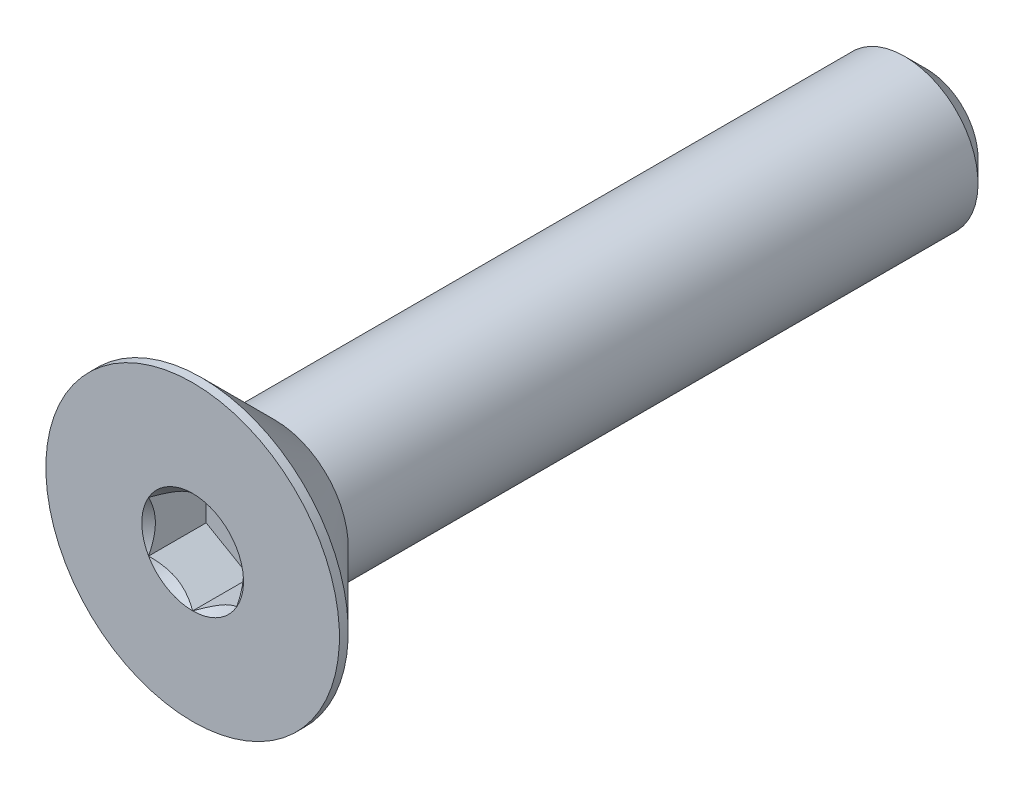
from build123d import *

# Parameters (mm, degrees)
SKETCH3_W          = 25
SKETCH3_H          = 2.5
CHAMFER1_SIZE      = 0.75
CUT_EXTRUDE1_DEPTH = 1.96
SKETCH9_R          = 1.732050808
CUT_EXTRUDE2_DEPTH = 1.96
CUT_EXTRUDE2_DRAFT = -45


with BuildPart() as part:
    # Sketch3 → Revolve1 (revolve)
    with BuildSketch(Plane(origin=(0, 0, 0), x_dir=(0, 0, -1), z_dir=(1, 0, 0))):
        with Locations((0, 1.25)):
            Rectangle(SKETCH3_W, SKETCH3_H)
    revolve(axis=Axis((0, 0, -12.5), (0, 0, 1)))

    # Chamfer1
    chamfer1_edges = [part.edges().sort_by_distance(p)[0] for p in [
        (0, -2.5, -12.5),
    ]]
    chamfer(chamfer1_edges, length=CHAMFER1_SIZE)

    # Sketch6 → Revolve2 (revolve)
    with BuildSketch(Plane(origin=(0, 0, 0), x_dir=(0, 0, -1), z_dir=(1, 0, 0))):
        Polygon((-12.5, 5), (-12.2, 5), (-9.7, 2.5), (-9.7, 0), (-12.5, 0), align=None)
    revolve(axis=Axis((0, 0, -12.5), (0, 0, 1)))

    # Sketch8 → Cut-Extrude1 (cut)
    with BuildSketch(Plane.XY.offset(12.5)):
        Polygon((0, 1.732050808), (-1.5, 0.866025404), (-1.5, -0.866025404), (0, -1.732050808), (1.5, -0.866025404), (1.5, 0.866025404), align=None)
    extrude(amount=-CUT_EXTRUDE1_DEPTH, mode=Mode.SUBTRACT)


with BuildPart() as cut_extrude2_tool:
    # Sketch9 → Cut-Extrude2 (with draft: the straight prism first)
    with BuildSketch(Plane.XY.offset(12.5)):
        Circle(SKETCH9_R)
    extrude(amount=-CUT_EXTRUDE2_DEPTH)
    # Cut-Extrude2: the draft: its side faces are tilted about the plane it starts from
    cut_extrude2_sides = [cut_extrude2_tool.faces().sort_by_distance(p)[0] for p in [
        (-1.732050808, 0, 11.52),
    ]]
    draft(cut_extrude2_sides, Plane.XY.offset(12.5), CUT_EXTRUDE2_DRAFT)


with BuildPart() as part_1:
    add(part.part)

    # Cut-Extrude2: cut by cut_extrude2_tool
    add(cut_extrude2_tool.part, mode=Mode.SUBTRACT)


solid = part_1.part
